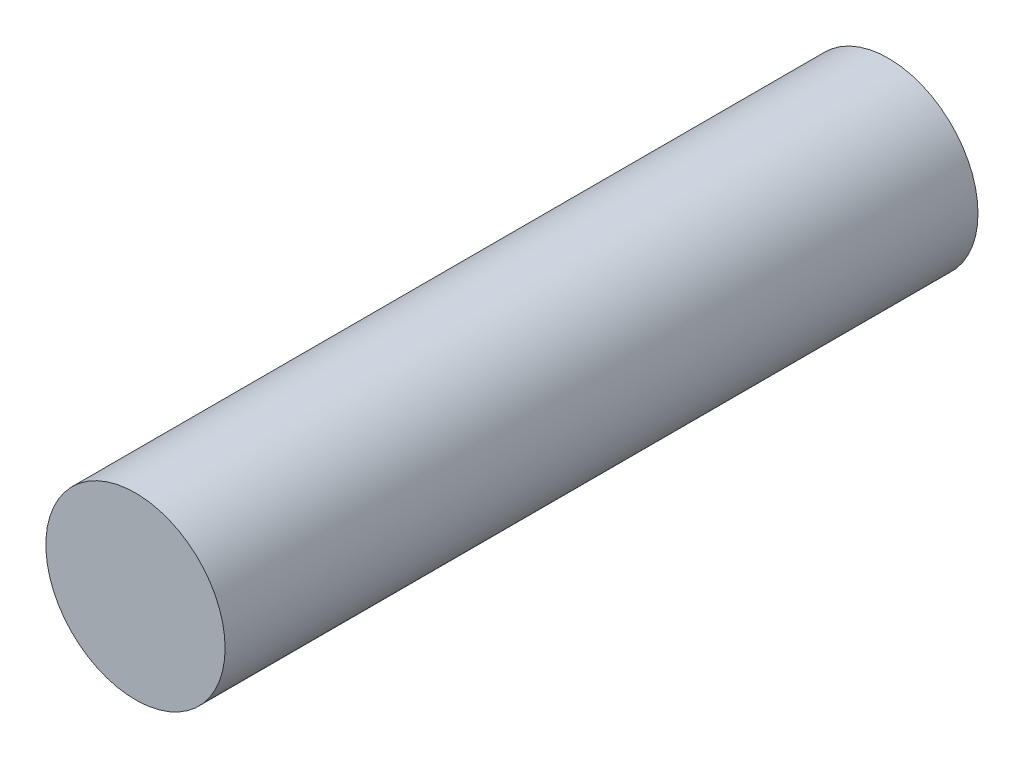
from build123d import *

# Parameters (mm, degrees)
SKETCH_1_R      = 3.75
EXTRUDE_1_DEPTH = 31.5


with BuildPart() as part:
    # Эскиз1 → Бобышка-Вытянуть1 (new body)
    with BuildSketch(Plane.XY):
        Circle(SKETCH_1_R)
    extrude(amount=EXTRUDE_1_DEPTH)


solid = part.part
